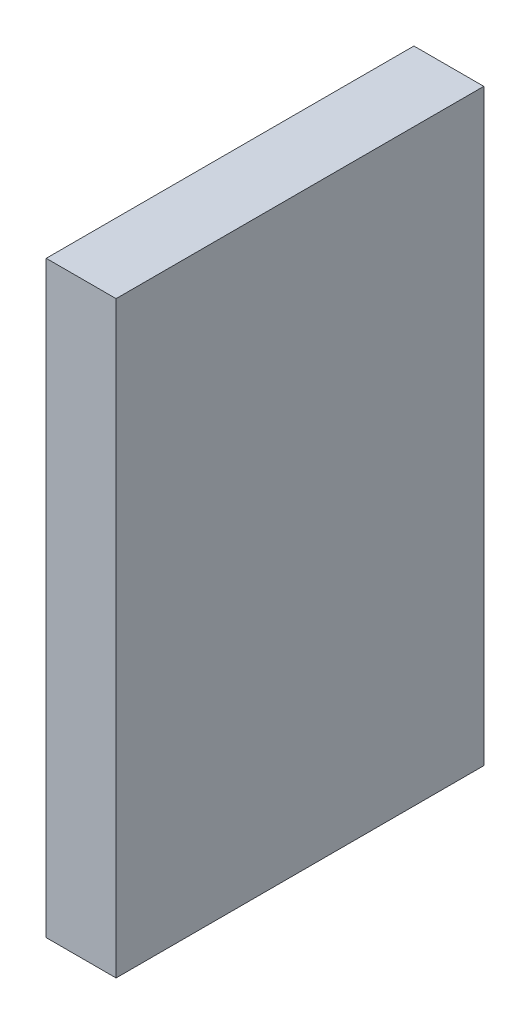
from build123d import *

# Parameters (mm, degrees)
SKETCH1_W           = 50
SKETCH1_H           = 80
BOSS_EXTRUDE1_DEPTH = 9.5


with BuildPart() as part:
    # Sketch1 → Boss-Extrude1 (new body)
    with BuildSketch(Plane(origin=(0, 0, 0), x_dir=(0, 0, -1), z_dir=(1, 0, 0))):
        Rectangle(SKETCH1_W, SKETCH1_H)
    extrude(amount=BOSS_EXTRUDE1_DEPTH)


solid = part.part
